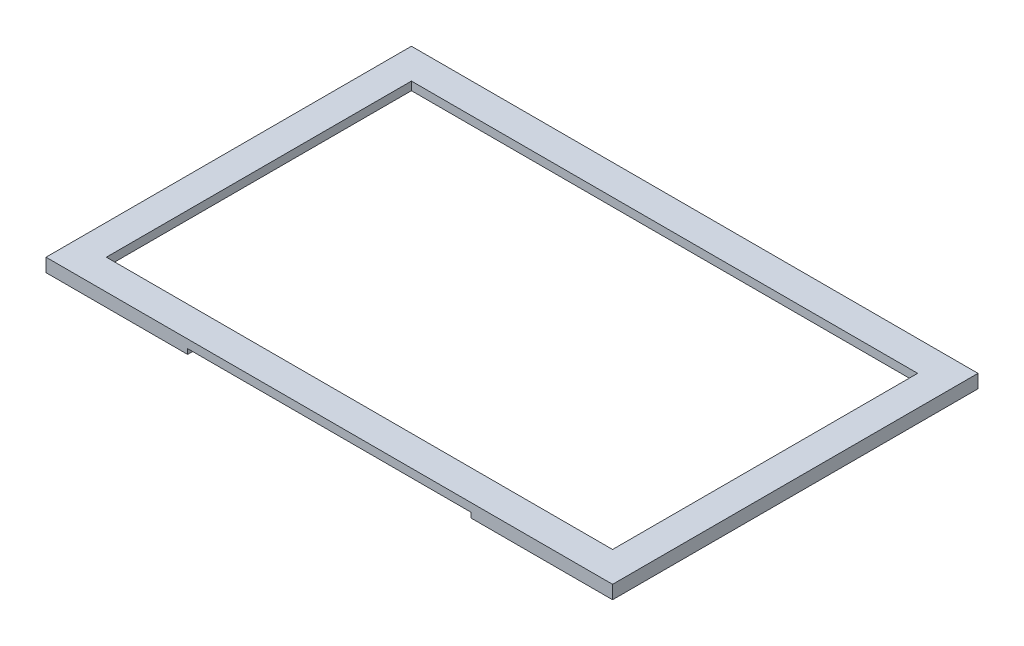
from build123d import *

# Parameters (mm, degrees)
SKETCH1_W           = 169
SKETCH1_H           = 4
BOSS_EXTRUDE1_DEPTH = 109
SKETCH3_W           = 165
SKETCH3_H           = 105
CUT_EXTRUDE1_DEPTH  = 1.5
SKETCH4_W           = 151
SKETCH4_H           = 91
CUT_EXTRUDE2_DEPTH  = 5
SKETCH5_W           = 84.5
SKETCH5_H           = 1.5
CUT_EXTRUDE3_DEPTH  = 2


with BuildPart() as part:
    # Sketch1 → Boss-Extrude1 (new body)
    with BuildSketch(Plane.XY):
        with Locations((84.5, 2)):
            Rectangle(SKETCH1_W, SKETCH1_H)
    extrude(amount=-BOSS_EXTRUDE1_DEPTH)

    # Sketch3 → Cut-Extrude1 (cut)
    with BuildSketch(Plane.XZ):
        with Locations((84.5, -54.5)):
            Rectangle(SKETCH3_W, SKETCH3_H)
    extrude(amount=-CUT_EXTRUDE1_DEPTH, mode=Mode.SUBTRACT)

    # Sketch4 → Cut-Extrude2 (cut)
    with BuildSketch(Plane(origin=(0, 4, 0), x_dir=(1, 0, 0), z_dir=(0, 1, 0))):
        with Locations((84.5, 54.5)):
            Rectangle(SKETCH4_W, SKETCH4_H)
    extrude(amount=-CUT_EXTRUDE2_DEPTH, mode=Mode.SUBTRACT)

    # Sketch5 → Cut-Extrude3 (cut)
    with BuildSketch(Plane.XY):
        with Locations((84.5, 0.75)):
            Rectangle(SKETCH5_W, SKETCH5_H)
    extrude(amount=-CUT_EXTRUDE3_DEPTH, mode=Mode.SUBTRACT)


solid = part.part
